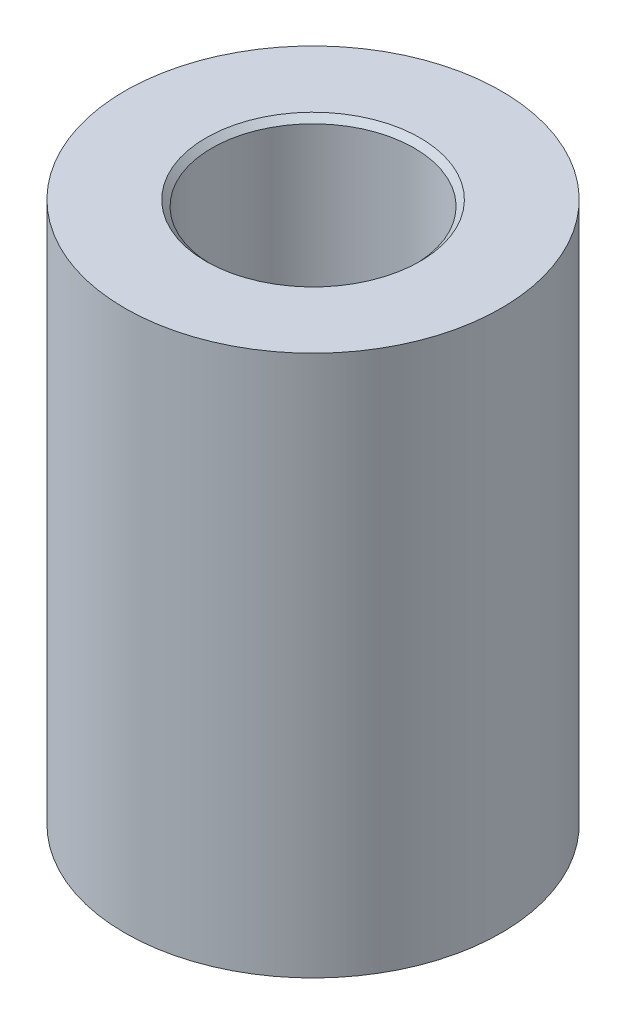
from build123d import *

# Parameters (mm, degrees)
SKETCH1_R                      = 4
BOSS_EXTRUDE1_DEPTH            = 5.75
M4_CLEARANCE_HOLE1_D           = 4.3
M4_CLEARANCE_HOLE1_CSINK_D     = 4.55
M4_CLEARANCE_HOLE1_CSINK_ANGLE = 90


with BuildPart() as part:
    # Sketch1 → Boss-Extrude1 (new body, symmetric)
    with BuildSketch(Plane(origin=(0, 0, 0), x_dir=(1, 0, 0), z_dir=(0, 1, 0))):
        Circle(SKETCH1_R)
    extrude(amount=BOSS_EXTRUDE1_DEPTH, both=True)

    # M4 Clearance Hole1 (through all)
    with Locations(Plane(origin=(0, 5.75, 0), x_dir=(1, 0, 0), z_dir=(0, 1, 0))):
        with Locations((0, 0)):
            CounterSinkHole(M4_CLEARANCE_HOLE1_D / 2, M4_CLEARANCE_HOLE1_CSINK_D / 2, counter_sink_angle=M4_CLEARANCE_HOLE1_CSINK_ANGLE)


solid = part.part
